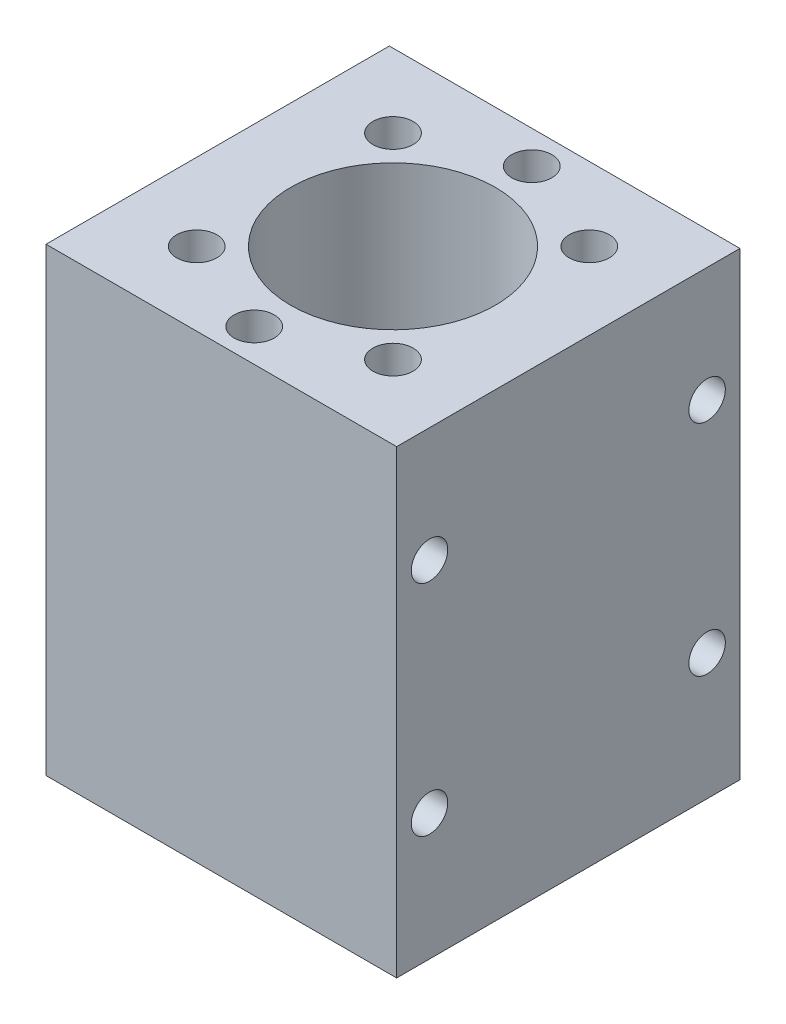
from build123d import *

# Parameters (mm, degrees)
SKETCH_1_W          = 48
SKETCH_1_H          = 47
SKETCH_1_R          = 14
EXTRUDE_1_DEPTH     = 63
SKETCH_2_R          = 2.5
CUT_EXTRUDE_1_DEPTH = 49
SKETCH_3_R          = 2.75
CUT_EXTRUDE_2_DEPTH = 10


with BuildPart() as part:
    # Эскиз1 → Бобышка-Вытянуть1 (new body)
    with BuildSketch(Plane(origin=(0, 0, 0), x_dir=(1, 0, 0), z_dir=(0, 1, 0))):
        Rectangle(SKETCH_1_W, SKETCH_1_H)
        Circle(SKETCH_1_R, mode=Mode.SUBTRACT)
    extrude(amount=EXTRUDE_1_DEPTH)

    # Эскиз2 → Вырез-Вытянуть1 (cut, through all)
    with BuildSketch(Plane.ZY.offset(24)):
        with Locations((-19.000000006, 47.3)):
            Circle(SKETCH_2_R)
        with Locations((-19.000000006, 17.3)):
            Circle(SKETCH_2_R)
        with Locations((18.999999994, 47.3)):
            Circle(SKETCH_2_R)
        with Locations((18.999999994, 17.3)):
            Circle(SKETCH_2_R)
    extrude(amount=-CUT_EXTRUDE_1_DEPTH, mode=Mode.SUBTRACT)

    # Эскиз3 → Вырез-Вытянуть2 (cut)
    with BuildSketch(Plane(origin=(0, 63, 0), x_dir=(1, 0, 0), z_dir=(0, 1, 0))):
        with Locations((13.435028843, -13.435028842)):
            Circle(SKETCH_3_R)
        with Locations((0, -19)):
            Circle(SKETCH_3_R)
        with Locations((-13.435028842, -13.435028842)):
            Circle(SKETCH_3_R)
        with Locations((13.435028843, 13.435028843)):
            Circle(SKETCH_3_R)
        with Locations((0, 19)):
            Circle(SKETCH_3_R)
        with Locations((-13.435028842, 13.435028843)):
            Circle(SKETCH_3_R)
    extrude(amount=-CUT_EXTRUDE_2_DEPTH, mode=Mode.SUBTRACT)


solid = part.part
